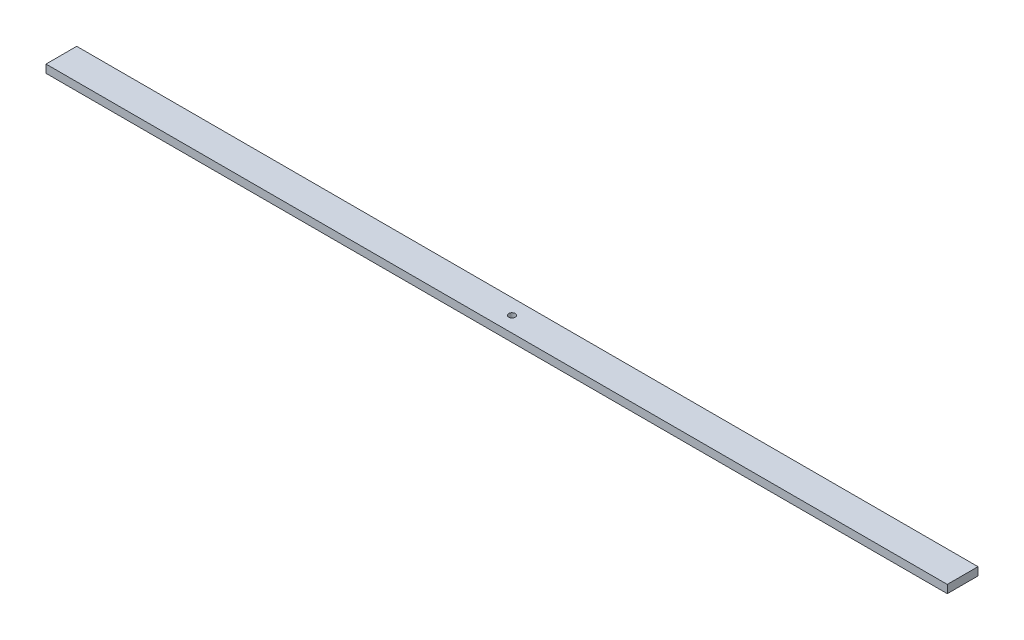
from build123d import *

# Parameters (mm, degrees)
SKETCH1_W           = 558.8
SKETCH1_H           = 19.05
SKETCH1_R           = 2
BOSS_EXTRUDE1_DEPTH = 5


with BuildPart() as part:
    # Sketch1 → Boss-Extrude1 (new body)
    with BuildSketch(Plane(origin=(0, 0, 0), x_dir=(1, 0, 0), z_dir=(0, 1, 0))):
        Rectangle(SKETCH1_W, SKETCH1_H)
        Circle(SKETCH1_R, mode=Mode.SUBTRACT)
    extrude(amount=BOSS_EXTRUDE1_DEPTH)


solid = part.part
